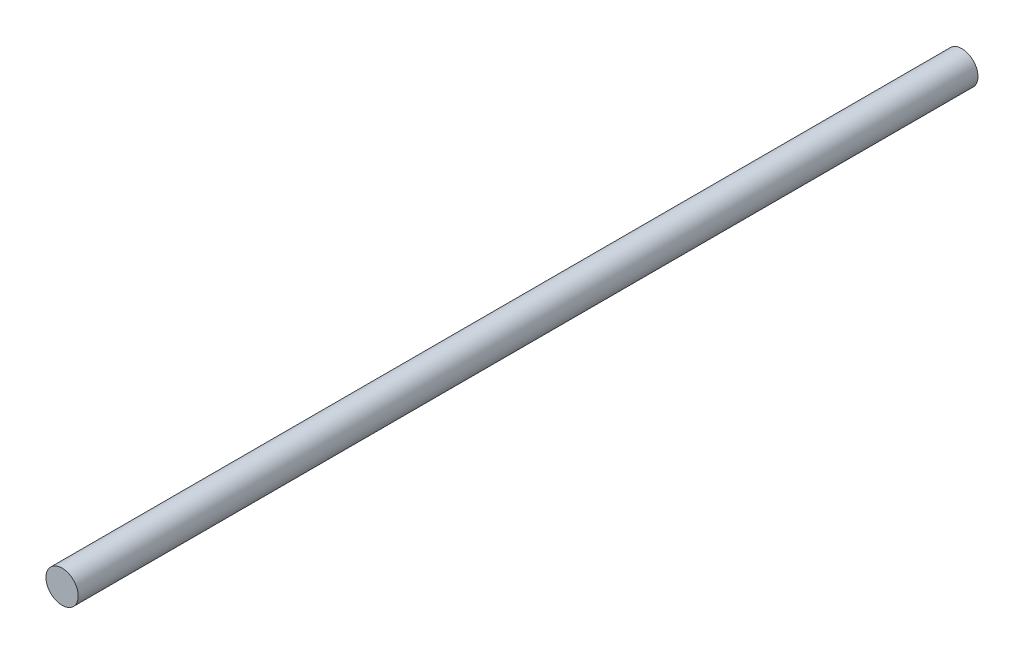
from build123d import *

# Parameters (mm, degrees)
SKETCH1_R           = 4
BOSS_EXTRUDE1_DEPTH = 223.3


with BuildPart() as part:
    # Sketch1 → Boss-Extrude1 (new body)
    with BuildSketch(Plane.XY):
        Circle(SKETCH1_R)
    extrude(amount=BOSS_EXTRUDE1_DEPTH)


solid = part.part
